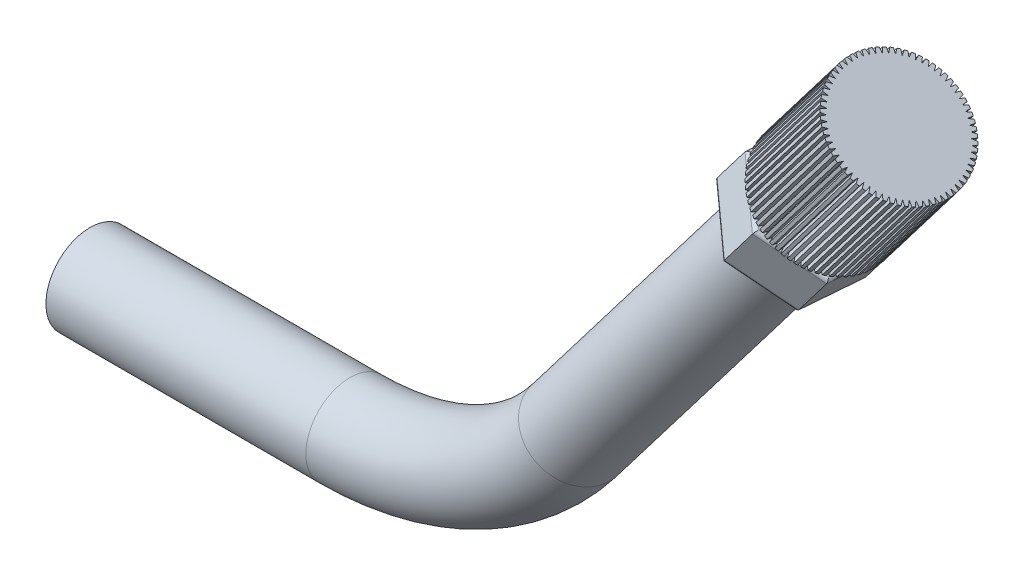
from build123d import *

# Parameters (mm, degrees)
SKETCH2_R           = 2.5
BOSS_EXTRUDE1_DEPTH = 3
SKETCH4_R           = 1
BOSS_EXTRUDE3_DEPTH = 0.25
SKETCH5_R           = 3.5
BOSS_EXTRUDE4_DEPTH = 7
CUT_EXTRUDE1_DEPTH  = 7
CIRPATTERN1_COUNT   = 68
FILLET2_R           = 0.2


with BuildPart() as part:
    # Sweep3: sweep along a path in Sketch1
    with BuildLine(Plane.XY) as sweep3_path:
        Line((39.593110203, 22.194042628), (27.454838136, 6.298686349))
        ThreePointArc((27.454838136, 6.298686349), (21.823545787, 1.660732822), (14.71974167, 0))
        Line((14.71974167, 0), (0, 0))
    # Sketch2 → Sweep3 (sweep)
    with BuildSketch(Plane(origin=(0, 0, 0), x_dir=(0, 0, -1), z_dir=(1, 0, 0))):
        Circle(SKETCH2_R)
    sweep(path=sweep3_path.line)

    # Sketch3 → Boss-Extrude1 (add)
    with BuildSketch(Plane(origin=(25.289305673, 33.116947905, 0), x_dir=(0.794767814, -0.606913603, 0), z_dir=(0.606913603, 0.794767814, 0))):
        Polygon((18.205462977, 3.618506523), (14.967744545, 1.989386302), (14.759744826, -1.629120221), (17.789463539, -3.618506523), (21.027181972, -1.989386302), (21.235181691, 1.629120221), align=None)
    extrude(amount=BOSS_EXTRUDE1_DEPTH)

    # Sketch4 → Boss-Extrude3 (add)
    with BuildSketch(Plane(origin=(27.110046483, 35.501251347, 0), x_dir=(0.794767814, -0.606913603, 0), z_dir=(0.606913603, 0.794767814, 0))):
        with Locations((17.997463258, 0)):
            Circle(SKETCH4_R)
    extrude(amount=BOSS_EXTRUDE3_DEPTH)

    # Sketch5 → Boss-Extrude4 (add)
    with BuildSketch(Plane(origin=(27.261774884, 35.699943301, 0), x_dir=(0.794767814, -0.606913603, 0), z_dir=(0.606913603, 0.794767814, 0))):
        with Locations((17.997463258, 0)):
            Circle(SKETCH5_R)
    extrude(amount=BOSS_EXTRUDE4_DEPTH)

    # Sketch6 → Cut-Extrude1 (cut)
    with BuildSketch(Plane(origin=(31.510170108, 41.263317998, 0), x_dir=(0.794767814, -0.606913603, 0), z_dir=(0.606913603, 0.794767814, 0))):
        with BuildLine():
            Line((17.922924261, 3.215738797), (17.989634453, 3.499991244))
            ThreePointArc((17.989634453, 3.499991244), (17.911651467, 3.593807923), (17.838235051, 3.496376178))
            Line((17.838235051, 3.496376178), (17.922924261, 3.215738797))
        make_face()
    cut_extrude1 = extrude(amount=-CUT_EXTRUDE1_DEPTH, mode=Mode.SUBTRACT)

    # CirPattern1: Cut-Extrude1 ×68 about axis
    cirpattern1_axis = Axis((14.30380453, -10.922905277, 0), (0.606913603, 0.794767814, 0))
    for i in range(1, CIRPATTERN1_COUNT):
        add(cut_extrude1.rotate(cirpattern1_axis, i * 360 / CIRPATTERN1_COUNT), mode=Mode.SUBTRACT)

    # Fillet2
    fillet2_edges = [part.edges().sort_by_distance(p)[0] for p in [
        (37.102531543, 24.095939059, -0.18013304),
        (38.223837262, 23.239669238, 2.623813372),
        (40.714415922, 21.337772807, 2.803946413),
        (42.083688863, 20.292146197, 0.18013304),
        (42.783123954, 23.53271946, -2.623813372),
        (40.292545295, 25.434615891, -2.803946413),
        (38.923272354, 26.480242501, -0.18013304),
        (40.044578072, 25.623972679, 2.623813372),
        (42.535156732, 23.722076248, 2.803946413),
        (43.904429673, 22.676449639, 0.18013304),
        (39.593110203, 22.194042628, 2.5),
        (40.619083199, 25.185259673, 0),
        (40.962383144, 21.148416018, -2.623813372),
        (38.471804485, 23.050312449, -2.803946413),
    ]]
    fillet(fillet2_edges, radius=FILLET2_R)


solid = part.part
